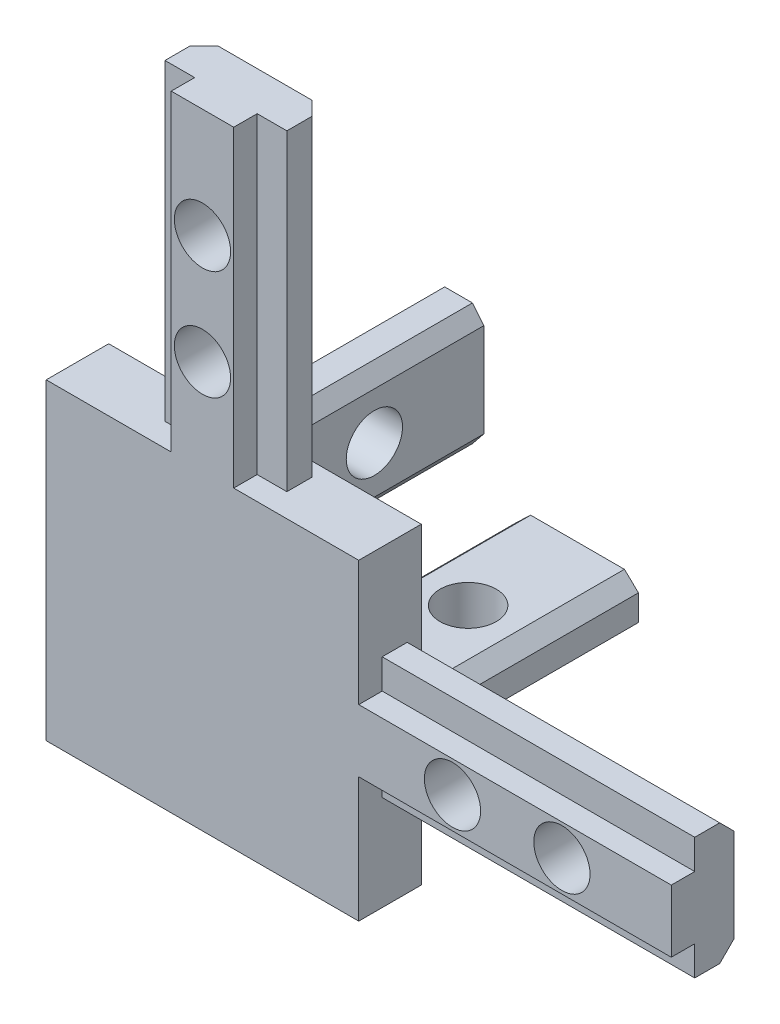
from build123d import *

# Parameters (mm, degrees)
SKETCH_1_W           = 20
SKETCH_1_H           = 20
EXTRUDE_1_DEPTH      = 4
SKETCH_2_W           = 14
SKETCH_2_H           = 14
CUT_EXTRUDE_1_DEPTH  = 2
EXTRUDE_2_DEPTH      = 20
EXTRUDE_3_DEPTH      = 20
EXTRUDE_4_DEPTH      = 20
EXTRUDE_4_DEPTH_BACK = 4
SKETCH_7_R           = 1.8
CUT_EXTRUDE_5_DEPTH  = 41
SKETCH_8_R           = 1.8
CUT_EXTRUDE_6_DEPTH  = 20
SKETCH_9_R           = 1.8
CUT_EXTRUDE_7_DEPTH  = 20


with BuildPart() as part:
    # 草图1 → 凸台-拉伸1 (new body)
    with BuildSketch(Plane.XY):
        Rectangle(SKETCH_1_W, SKETCH_1_H)
    extrude(amount=EXTRUDE_1_DEPTH)

    # 草图2 → 切除-拉伸1 (cut)
    with BuildSketch(Plane(origin=(0, 0, 0), x_dir=(-1, 0, 0), z_dir=(0, 0, -1))):
        Rectangle(SKETCH_2_W, SKETCH_2_H)
    extrude(amount=-CUT_EXTRUDE_1_DEPTH, mode=Mode.SUBTRACT)

    # 草图3 → 凸台-拉伸2 (add)
    with BuildSketch(Plane(origin=(10, 0, 0), x_dir=(0, 0, -1), z_dir=(1, 0, 0))):
        Polygon((-4, -2), (-4, 2), (-2.5, 2), (-2.5, 3.9), (-0.9, 3.9), (0, 3), (0, -3), (-0.9, -3.9), (-2.5, -3.9), (-2.5, -2), align=None)
    extrude(amount=EXTRUDE_2_DEPTH)

    # 草图5 → 凸台-拉伸3 (add)
    with BuildSketch(Plane(origin=(0, 10, 0), x_dir=(1, 0, 0), z_dir=(0, 1, 0))):
        Polygon((2, -4), (-2, -4), (-2, -2.5), (-3.9, -2.5), (-3.9, -0.9), (-3, 0), (3, 0), (3.9, -0.9), (3.9, -2.5), (2, -2.5), align=None)
    extrude(amount=EXTRUDE_3_DEPTH)

    # 草图6 → 凸台-拉伸4 (add, two sides)
    with BuildSketch(Plane(origin=(0, 0, 0), x_dir=(-1, 0, 0), z_dir=(0, 0, -1))) as extrude_4_sk:
        Polygon((10, 2), (10, -2), (8.5, -2), (8.5, -3.9), (6.723155125, -3.9), (6, -3), (6, 3), (6.723155125, 3.9), (8.5, 3.9), (8.5, 2), align=None)
        Polygon((2, -10), (-2, -10), (-2, -8.5), (-3.9, -8.5), (-3.9, -6.853318906), (-3, -6), (3, -6), (3.9, -6.853318906), (3.9, -8.5), (2, -8.5), align=None)
    extrude(amount=EXTRUDE_4_DEPTH)
    extrude(extrude_4_sk.sketch, amount=-EXTRUDE_4_DEPTH_BACK)

    # 草图7 → 切除-拉伸5 (cut, through all)
    with BuildSketch(Plane.ZY.offset(10)):
        with Locations((-6, 0)):
            Circle(SKETCH_7_R)
        with Locations((-13, 0)):
            Circle(SKETCH_7_R)
    extrude(amount=-CUT_EXTRUDE_5_DEPTH, mode=Mode.SUBTRACT)

    # 草图8 → 切除-拉伸6 (cut)
    with BuildSketch(Plane(origin=(0, 0, 0), x_dir=(-1, 0, 0), z_dir=(0, 0, -1))):
        with Locations((-16, 0)):
            Circle(SKETCH_8_R)
        with Locations((0, 16)):
            Circle(SKETCH_8_R)
        with Locations((0, 23)):
            Circle(SKETCH_8_R)
        with Locations((-23, 0)):
            Circle(SKETCH_8_R)
    extrude(amount=-CUT_EXTRUDE_6_DEPTH, mode=Mode.SUBTRACT)

    # 草图9 → 切除-拉伸7 (cut)
    with BuildSketch(Plane.XZ.offset(10)):
        with Locations((0, -6)):
            Circle(SKETCH_9_R)
        with Locations((0, -13)):
            Circle(SKETCH_9_R)
    extrude(amount=-CUT_EXTRUDE_7_DEPTH, mode=Mode.SUBTRACT)


solid = part.part
